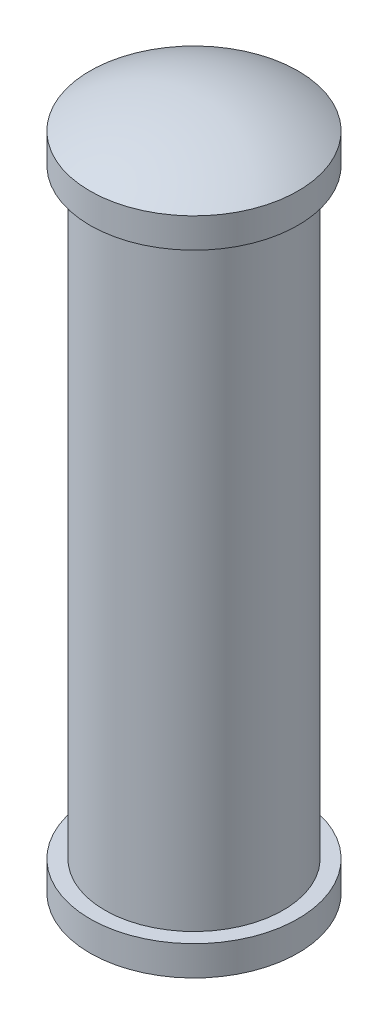
from build123d import *

# Parameters (mm, degrees)
SKETCH1_W                  = 3
SKETCH1_H                  = 10.1
SKETCH2_R                  = 3.5
BOSS_EXTRUDE1_DEPTH        = 1
DOME1_FACE_RADIUS          = 3.5
DOME1_HEIGHT               = 1
MIRROR1_COPY_1_FACE_RADIUS = 3.5
MIRROR1_COPY_1_HEIGHT      = 1


with BuildPart() as part:
    # Sketch1 → Revolve1 (revolve)
    with BuildSketch(Plane.XY, mode=Mode.PRIVATE) as revolve1_sk:
        with Locations((-1.5, 5.05)):
            Rectangle(SKETCH1_W, SKETCH1_H)
    revolve1 = revolve(revolve1_sk.sketch.rotate(Axis((0, 5.950819672, 0), (0, -1, 0)), 270), axis=Axis((0, 5.950819672, 0), (0, -1, 0)))

    # Sketch2 → Boss-Extrude1 (add)
    with BuildSketch(Plane(origin=(0, 10.1, 0), x_dir=(1, 0, 0), z_dir=(0, 1, 0))):
        with Locations(Location((0, 0, 0), (0, 0, 270))):
            Circle(SKETCH2_R)
    boss_extrude1 = extrude(amount=BOSS_EXTRUDE1_DEPTH)

    # Dome1: a dome of height H over a round flat face of radius A is a cap of a sphere of radius (A * A + H * H) / (2 * H)
    dome1_r = (DOME1_FACE_RADIUS * DOME1_FACE_RADIUS + DOME1_HEIGHT * DOME1_HEIGHT) / (2 * DOME1_HEIGHT)
    dome1_base = Plane((0, 11.1, 0), z_dir=(0, 1, 0))
    with Locations(dome1_base.offset(DOME1_HEIGHT - dome1_r)):
        dome1_ball = Sphere(dome1_r, mode=Mode.PRIVATE)
    add(split(dome1_ball, bisect_by=dome1_base, keep=Keep.TOP, mode=Mode.PRIVATE))

    # Mirror1: Revolve1, Boss-Extrude1 across plane
    add(revolve1.mirror(Plane.ZX))
    add(boss_extrude1.mirror(Plane.ZX))

    # Mirror1 copy 1: a dome of height H over a round flat face of radius A is a cap of a sphere of radius (A * A + H * H) / (2 * H)
    mirror1_copy_1_r = (MIRROR1_COPY_1_FACE_RADIUS * MIRROR1_COPY_1_FACE_RADIUS + MIRROR1_COPY_1_HEIGHT * MIRROR1_COPY_1_HEIGHT) / (2 * MIRROR1_COPY_1_HEIGHT)
    mirror1_copy_1_base = Plane((0, -11.1, 0), z_dir=(0, -1, 0))
    with Locations(mirror1_copy_1_base.offset(MIRROR1_COPY_1_HEIGHT - mirror1_copy_1_r)):
        mirror1_copy_1_ball = Sphere(mirror1_copy_1_r, mode=Mode.PRIVATE)
    add(split(mirror1_copy_1_ball, bisect_by=mirror1_copy_1_base, keep=Keep.TOP, mode=Mode.PRIVATE))


solid = part.part
